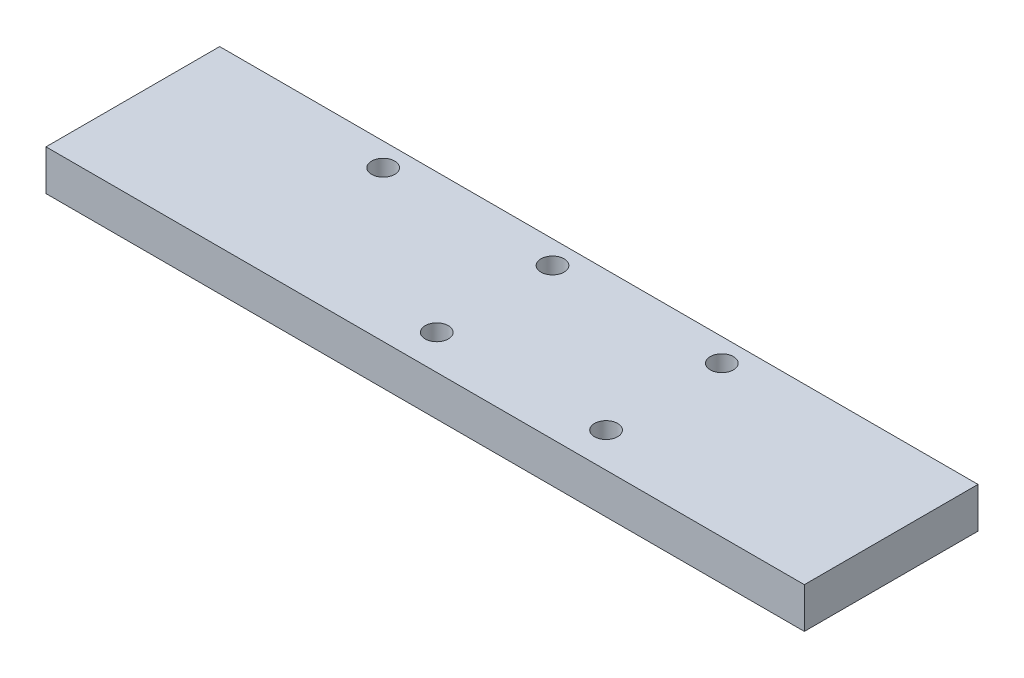
from build123d import *

# Parameters (mm, degrees)
SKETCH1_W           = 131
SKETCH1_H           = 30
BOSS_EXTRUDE1_DEPTH = 7
SKETCH2_R           = 2
CUT_EXTRUDE1_DEPTH  = 10


with BuildPart() as part:
    # Sketch1 → Boss-Extrude1 (new body)
    with BuildSketch(Plane(origin=(0, 0, 0), x_dir=(1, 0, 0), z_dir=(0, 1, 0))):
        with Locations((-37.010460251, 50.167364017)):
            Rectangle(SKETCH1_W, SKETCH1_H)
    extrude(amount=BOSS_EXTRUDE1_DEPTH)

    # Sketch2 → Cut-Extrude1 (cut)
    with BuildSketch(Plane.XZ):
        with Locations((-70.260460251, -61.167364017)):
            Circle(SKETCH2_R)
        with Locations((-41.010460251, -61.167364017)):
            Circle(SKETCH2_R)
        with Locations((-11.760460251, -61.167364017)):
            Circle(SKETCH2_R)
        with Locations((-11.760460251, -41.167364017)):
            Circle(SKETCH2_R)
        with Locations((-41.010460251, -41.167364017)):
            Circle(SKETCH2_R)
    extrude(amount=-CUT_EXTRUDE1_DEPTH, mode=Mode.SUBTRACT)


solid = part.part
